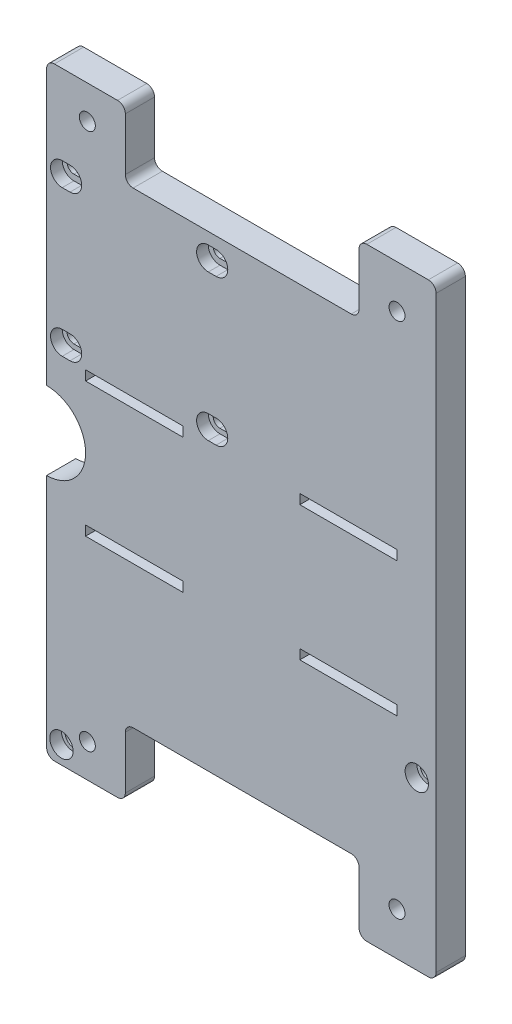
from build123d import *

# Parameters (mm, degrees)
SKETCH1_W                 = 100
SKETCH1_H                 = 155
BOSS_EXTRUDE1_DEPTH       = 7.5
SKETCH2_R                 = 2.05
SKETCH2_W                 = 60
SKETCH2_H                 = 17.5
HOLE_CUTOUTS_DEPTH        = 8.5
SKETCH3_W                 = 25
SKETCH3_H                 = 2.5
BATTERY_STRAP_HOLES_DEPTH = 8.5
H_BRIDGE_HOLES_DEPTH      = 7.5
FILLET1_R                 = 2
CAMERA_WIRE_HOLE_DEPTH    = 8.5
SKETCH10_R                = 2.05
CUT_EXTRUDE1_DEPTH        = 7.5
SKETCH11_R                = 3
CUT_EXTRUDE2_DEPTH        = 3


with BuildPart() as part:
    # Sketch1 → Boss-Extrude1 (new body)
    with BuildSketch(Plane.XY):
        with Locations((50, 77.5)):
            Rectangle(SKETCH1_W, SKETCH1_H)
    extrude(amount=BOSS_EXTRUDE1_DEPTH)

    # Sketch2 → Hole cutouts (cut, through all)
    with BuildSketch(Plane.XY.offset(7.5)):
        with Locations((10.45, 146.45)):
            Circle(SKETCH2_R)
        with Locations((89.95, 143.95)):
            Circle(SKETCH2_R)
        with Locations((89.95, 11.05)):
            Circle(SKETCH2_R)
        with Locations((10.45, 8.55)):
            Circle(SKETCH2_R)
        with Locations((50.2, 146.25)):
            Rectangle(SKETCH2_W, SKETCH2_H)
        with Locations((50.2, 8.75)):
            Rectangle(SKETCH2_W, SKETCH2_H)
    extrude(amount=-HOLE_CUTOUTS_DEPTH, mode=Mode.SUBTRACT)

    # Sketch3 → Battery strap holes (cut, through all)
    with BuildSketch(Plane.XY.offset(7.5)):
        with Locations((22.5, 89.75)):
            Rectangle(SKETCH3_W, SKETCH3_H)
        with Locations((77.5, 89.75)):
            Rectangle(SKETCH3_W, SKETCH3_H)
        with Locations((22.5, 55.25)):
            Rectangle(SKETCH3_W, SKETCH3_H)
        with Locations((77.5, 55.25)):
            Rectangle(SKETCH3_W, SKETCH3_H)
    extrude(amount=-BATTERY_STRAP_HOLES_DEPTH, mode=Mode.SUBTRACT)

    # Sketch4 → H-Bridge Holes (cut)
    with BuildSketch(Plane.XY.offset(7.5)):
        with BuildLine():
            Line((6, 133.51), (4, 133.51))
            ThreePointArc((4, 133.51), (2.25, 131.76), (4, 130.01))
            Line((4, 130.01), (5, 130.01))
            Line((5, 130.01), (5, 131.76))
            Line((5, 131.76), (7.75, 131.76))
            ThreePointArc((7.75, 131.76), (7.237436867, 132.997436867), (6, 133.51))
        make_face()
        with BuildLine():
            ThreePointArc((6, 130.01), (7.237436867, 130.522563133), (7.75, 131.76))
            Line((7.75, 131.76), (5, 131.76))
            Line((5, 131.76), (5, 130.01))
            Line((5, 130.01), (6, 130.01))
        make_face()
        with BuildLine():
            Line((42.5, 131.76), (39.75, 131.76))
            ThreePointArc((39.75, 131.76), (40.262563133, 130.522563133), (41.5, 130.01))
            Line((41.5, 130.01), (42.5, 130.01))
            Line((42.5, 130.01), (42.5, 131.76))
        make_face()
        with BuildLine():
            ThreePointArc((41.5, 133.51), (40.262563133, 132.997436867), (39.75, 131.76))
            Line((39.75, 131.76), (42.5, 131.76))
            Line((42.5, 131.76), (42.5, 130.01))
            Line((42.5, 130.01), (43.5, 130.01))
            ThreePointArc((43.5, 130.01), (45.25, 131.76), (43.5, 133.51))
            Line((43.5, 133.51), (41.5, 133.51))
        make_face()
        with BuildLine():
            Line((5, 94), (5, 95.75))
            Line((5, 95.75), (4, 95.75))
            ThreePointArc((4, 95.75), (2.25, 94), (4, 92.25))
            Line((4, 92.25), (6, 92.25))
            ThreePointArc((6, 92.25), (7.237436867, 92.762563133), (7.75, 94))
            Line((7.75, 94), (5, 94))
        make_face()
        with BuildLine():
            Line((6, 95.75), (5, 95.75))
            Line((5, 95.75), (5, 94))
            Line((5, 94), (7.75, 94))
            ThreePointArc((7.75, 94), (7.237436867, 95.237436867), (6, 95.75))
        make_face()
        with BuildLine():
            Line((43.5, 95.75), (42.5, 95.75))
            Line((42.5, 95.75), (42.5, 94))
            Line((42.5, 94), (39.75, 94))
            ThreePointArc((39.75, 94), (40.262563133, 92.762563133), (41.5, 92.25))
            Line((41.5, 92.25), (43.5, 92.25))
            ThreePointArc((43.5, 92.25), (45.25, 94), (43.5, 95.75))
        make_face()
        with BuildLine():
            Line((42.5, 94), (42.5, 95.75))
            Line((42.5, 95.75), (41.5, 95.75))
            ThreePointArc((41.5, 95.75), (40.262563133, 95.237436867), (39.75, 94))
            Line((39.75, 94), (42.5, 94))
        make_face()
    extrude(amount=-H_BRIDGE_HOLES_DEPTH, mode=Mode.SUBTRACT)

    # Fillet1
    fillet1_edges = [part.edges().sort_by_distance(p)[0] for p in [
        (20.2, 0, 3.75),
        (20.2, 17.5, 3.75),
        (80.2, 17.5, 3.75),
        (80.2, 0, 3.75),
        (20.2, 137.5, 3.75),
        (20.2, 155, 3.75),
        (80.2, 155, 3.75),
        (80.2, 137.5, 3.75),
        (0, 155, 3.75),
        (100, 155, 3.75),
        (100, 0, 3.75),
        (0, 0, 3.75),
    ]]
    fillet(fillet1_edges, radius=FILLET1_R)

    # Sketch9 → Camera Wire Hole (cut, through all)
    with BuildSketch(Plane.XY.offset(7.5)):
        with BuildLine():
            Line((0, 82.5), (0, 62.5))
            ThreePointArc((0, 62.5), (10, 72.5), (0, 82.5))
        make_face()
    extrude(amount=-CAMERA_WIRE_HOLE_DEPTH, mode=Mode.SUBTRACT)

    # Sketch10 → Cut-Extrude1 (cut)
    with BuildSketch(Plane.XY.offset(7.5)):
        with Locations((3.8, 4.55)):
            Circle(SKETCH10_R)
        with Locations((95.025, 42.825)):
            Circle(SKETCH10_R)
    extrude(amount=-CUT_EXTRUDE1_DEPTH, mode=Mode.SUBTRACT)

    # Sketch11 → Cut-Extrude2 (cut)
    with BuildSketch(Plane.XY.offset(7.5)):
        with Locations((3.8, 4.55)):
            Circle(SKETCH11_R)
        with Locations((95.025, 42.825)):
            Circle(SKETCH11_R)
        with BuildLine():
            Line((4, 97), (6, 97))
            ThreePointArc((6, 97), (9, 94), (6, 91))
            Line((6, 91), (4, 91))
            ThreePointArc((4, 91), (1, 94), (4, 97))
        make_face()
        with BuildLine():
            Line((41.5, 91), (43.5, 91))
            ThreePointArc((43.5, 91), (46.5, 94), (43.5, 97))
            Line((43.5, 97), (41.5, 97))
            ThreePointArc((41.5, 97), (38.5, 94), (41.5, 91))
        make_face()
        with BuildLine():
            Line((41.5, 128.5), (43.5, 128.5))
            ThreePointArc((43.5, 128.5), (46.5, 131.5), (43.5, 134.5))
            Line((43.5, 134.5), (41.5, 134.5))
            ThreePointArc((41.5, 134.5), (38.5, 131.5), (41.5, 128.5))
        make_face()
        with BuildLine():
            Line((4, 128.5), (6, 128.5))
            ThreePointArc((6, 128.5), (9, 131.5), (6, 134.5))
            Line((6, 134.5), (4, 134.5))
            ThreePointArc((4, 134.5), (1, 131.5), (4, 128.5))
        make_face()
    extrude(amount=-CUT_EXTRUDE2_DEPTH, mode=Mode.SUBTRACT)


solid = part.part
